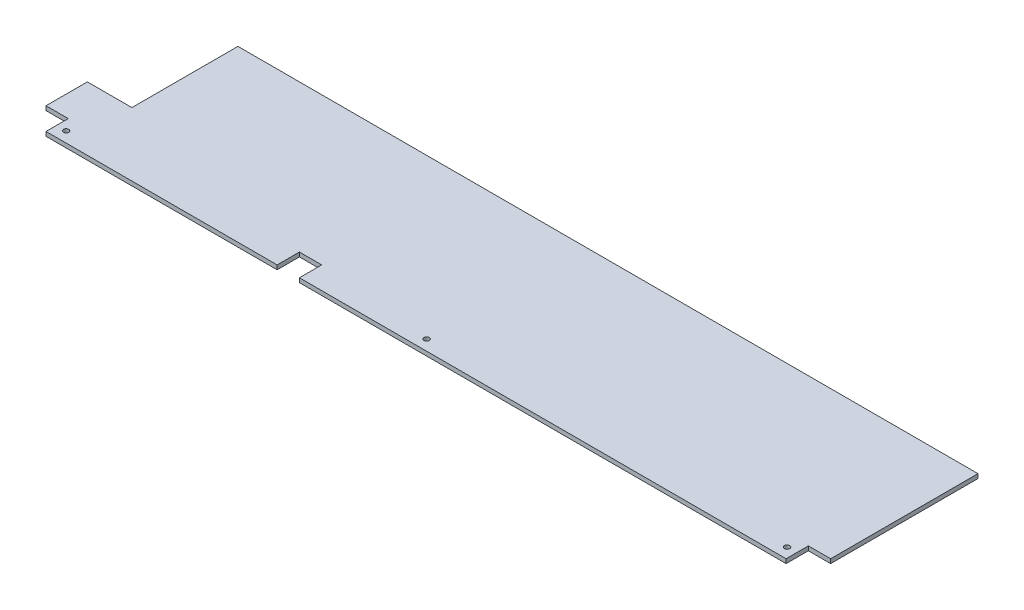
from build123d import *

# Parameters (mm, degrees)
SKETCH1_R           = 2.5
BOSS_EXTRUDE1_DEPTH = 4


with BuildPart() as part:
    # Sketch1 → Boss-Extrude1 (new body)
    with BuildSketch(Plane(origin=(0, 0, 0), x_dir=(1, 0, 0), z_dir=(0, 1, 0))):
        Polygon((-370, -69), (-370, -30), (-328, -30), (-328, 70), (370, 70), (370, -69), (349, -69), (349, -90), (-110, -90), (-110, -69), (-131, -69), (-131, -90), (-349, -90), (-349, -69), align=None)
        with Locations((-340, -80)):
            Circle(SKETCH1_R, mode=Mode.SUBTRACT)
        with Locations((0, -80)):
            Circle(SKETCH1_R, mode=Mode.SUBTRACT)
        with Locations((340, -80)):
            Circle(SKETCH1_R, mode=Mode.SUBTRACT)
    extrude(amount=BOSS_EXTRUDE1_DEPTH)


solid = part.part
